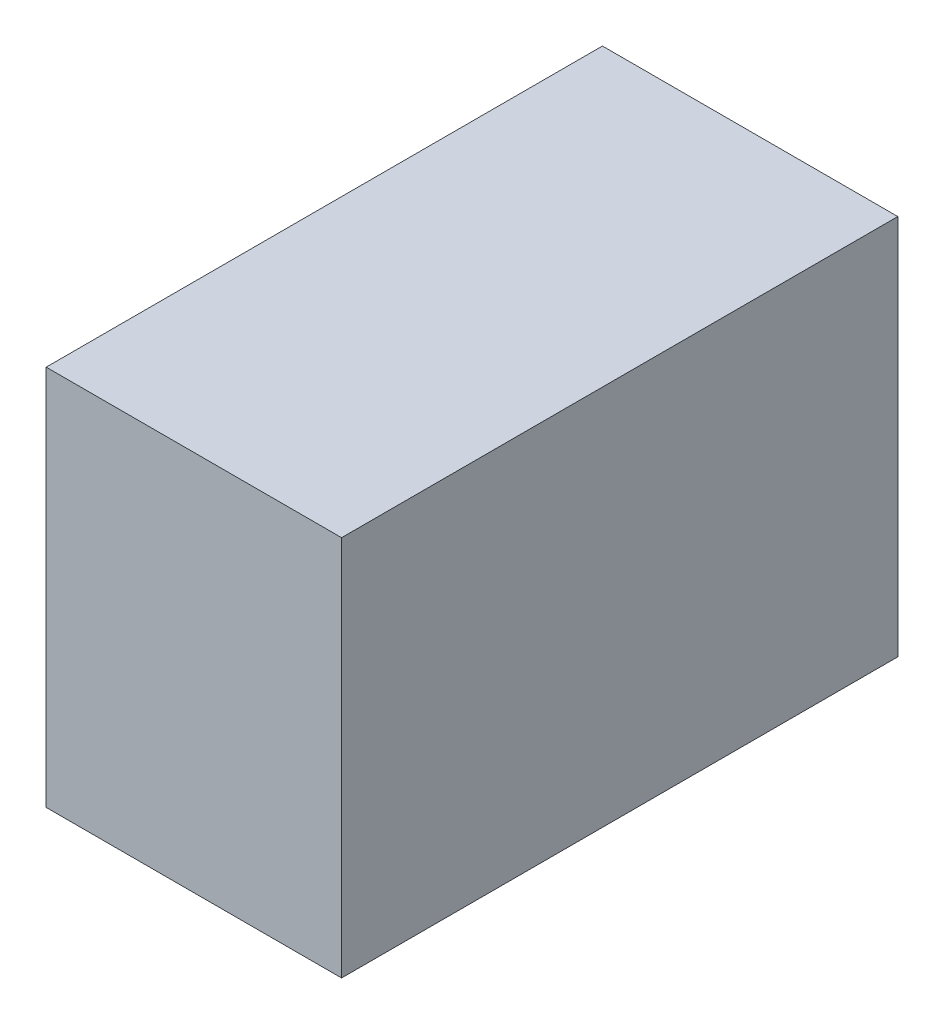
from build123d import *

# Parameters (mm, degrees)
SKETCH1_W           = 23.78
SKETCH1_H           = 30.7
BOSS_EXTRUDE1_DEPTH = 44.78


with BuildPart() as part:
    # Sketch1 → Boss-Extrude1 (new body)
    with BuildSketch(Plane.XY):
        with Locations((18.11, 38.4911038)):
            Rectangle(SKETCH1_W, SKETCH1_H)
    extrude(amount=BOSS_EXTRUDE1_DEPTH)


solid = part.part
